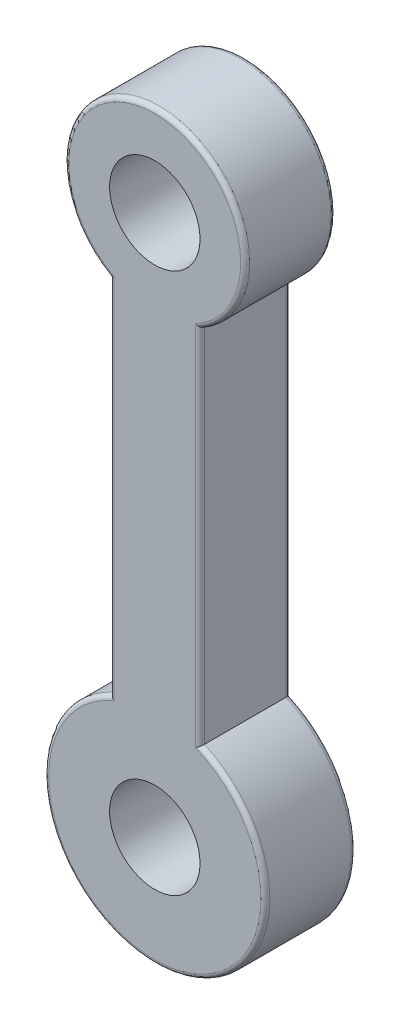
from build123d import *

# Parameters (mm, degrees)
ESQUISSE1_R        = 10
BOSS_EXTRU_1_DEPTH = 20
CONG_2_R           = 1


with BuildPart() as part:
    # Esquisse1 → Boss.-Extru.1 (new body)
    with BuildSketch(Plane.XY):
        with BuildLine():
            Line((-10, -17.320508076), (-10, -97.320508076))
            ThreePointArc((-10, -97.320508076), (0, -144.099247501), (10, -97.320508076))
            Line((10, -97.320508076), (10, -17.320508076))
            ThreePointArc((10, -17.320508076), (0, 20), (-10, -17.320508076))
        make_face()
        Circle(ESQUISSE1_R, mode=Mode.SUBTRACT)
        with Locations((0, -119.641016151)):
            Circle(ESQUISSE1_R, mode=Mode.SUBTRACT)
    extrude(amount=BOSS_EXTRU_1_DEPTH)

    # Congé2
    cong_2_edges = [part.edges().sort_by_distance(p)[0] for p in [
        (0, -144.099247501, 20),
        (10, -57.320508076, 20),
        (0, 20, 20),
        (10, -57.320508076, 0),
        (0, -144.099247501, 0),
        (-10, -57.320508076, 0),
        (0, 20, 0),
        (-10, -57.320508076, 20),
    ]]
    fillet(cong_2_edges, radius=CONG_2_R)


solid = part.part
